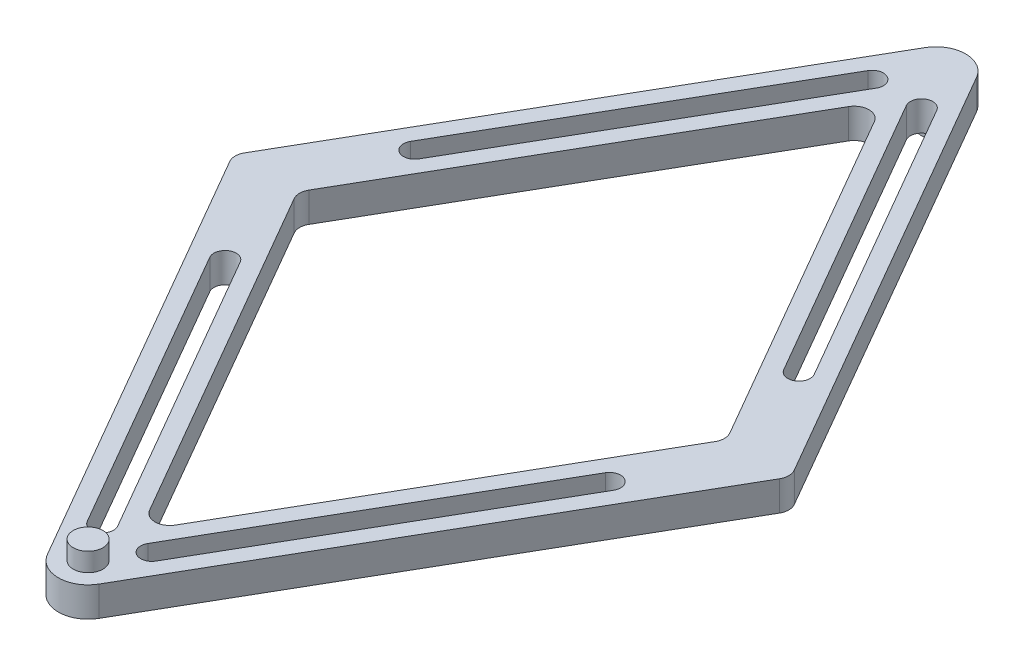
from build123d import *

# Parameters (mm, degrees)
EXTRUDE_1_DEPTH     = 8
FILLET_1_R          = 8
FILLET_2_R          = 4
FILLET_3_R          = 4
CUT_EXTRUDE_1_DEPTH = 9
SKETCH_3_R          = 4
EXTRUDE_2_DEPTH     = 5
SKETCH_4_R          = 4
EXTRUDE_3_DEPTH     = 5


with BuildPart() as part:
    # 草图1 → 凸台-拉伸1 (new body)
    with BuildSketch(Plane(origin=(0, 0, 0), x_dir=(1, 0, 0), z_dir=(0, 1, 0))):
        Polygon((0, -130), (-75.055534995, 0), (0, 130), (75.055534995, 0), align=None)
        Polygon((57.735026919, 0), (0, -100), (-57.735026919, 0), (0, 100), align=None, mode=Mode.SUBTRACT)
    extrude(amount=EXTRUDE_1_DEPTH)

    # 圆角1
    fillet_1_edges = [part.edges().sort_by_distance(p)[0] for p in [
        (0, 4, -130),
        (0, 4, 130),
    ]]
    fillet(fillet_1_edges, radius=FILLET_1_R)

    # 圆角2
    fillet_2_edges = [part.edges().sort_by_distance(p)[0] for p in [
        (0, 4, -100),
        (0, 4, 100),
    ]]
    fillet(fillet_2_edges, radius=FILLET_2_R)

    # 圆角3
    fillet_3_edges = [part.edges().sort_by_distance(p)[0] for p in [
        (57.735026919, 4, 0),
        (-57.735026919, 4, 0),
        (75.055534995, 4, 0),
        (-75.055534995, 4, 0),
    ]]
    fillet(fillet_3_edges, radius=FILLET_3_R)

    # 草图2 → 切除-拉伸1 (cut, through all)
    with BuildSketch(Plane(origin=(0, 8, 0), x_dir=(1, 0, 0), z_dir=(0, 1, 0))):
        with BuildLine():
            Line((-9.243452109, -104.989871311), (-54.277652929, -26.988347411))
            ThreePointArc((-54.277652929, -26.988347411), (-53.179576718, -22.8902712), (-49.081500506, -23.988347411))
            Line((-49.081500506, -23.988347411), (-4.047299686, -101.989871311))
            ThreePointArc((-4.047299686, -101.989871311), (-5.145375897, -106.087947522), (-9.243452109, -104.989871311))
        make_face()
        with BuildLine():
            Line((9.243452109, -104.989871311), (54.277652929, -26.988347411))
            ThreePointArc((54.277652929, -26.988347411), (53.179576718, -22.8902712), (49.081500506, -23.988347411))
            Line((49.081500506, -23.988347411), (4.047299686, -101.989871311))
            ThreePointArc((4.047299686, -101.989871311), (5.145375897, -106.087947522), (9.243452109, -104.989871311))
        make_face()
        with BuildLine():
            Line((9.243452109, 104.989871311), (54.277652929, 26.988347411))
            ThreePointArc((54.277652929, 26.988347411), (53.179576718, 22.8902712), (49.081500506, 23.988347411))
            Line((49.081500506, 23.988347411), (4.047299686, 101.989871311))
            ThreePointArc((4.047299686, 101.989871311), (5.145375897, 106.087947522), (9.243452109, 104.989871311))
        make_face()
        with BuildLine():
            Line((-9.243452109, 104.989871311), (-54.277652929, 26.988347411))
            ThreePointArc((-54.277652929, 26.988347411), (-53.179576718, 22.8902712), (-49.081500506, 23.988347411))
            Line((-49.081500506, 23.988347411), (-4.047299686, 101.989871311))
            ThreePointArc((-4.047299686, 101.989871311), (-5.145375897, 106.087947522), (-9.243452109, 104.989871311))
        make_face()
    extrude(amount=-CUT_EXTRUDE_1_DEPTH, mode=Mode.SUBTRACT)

    # 草图3 → 凸台-拉伸2 (add)
    with BuildSketch(Plane(origin=(0, 8, 0), x_dir=(1, 0, 0), z_dir=(0, 1, 0))):
        with Locations((0, -114)):
            Circle(SKETCH_3_R)
    extrude(amount=EXTRUDE_2_DEPTH)

    # 草图4 → 凸台-拉伸3 (add)
    with BuildSketch(Plane.XZ):
        with Locations((0, -114)):
            Circle(SKETCH_4_R)
    extrude(amount=EXTRUDE_3_DEPTH)


solid = part.part
